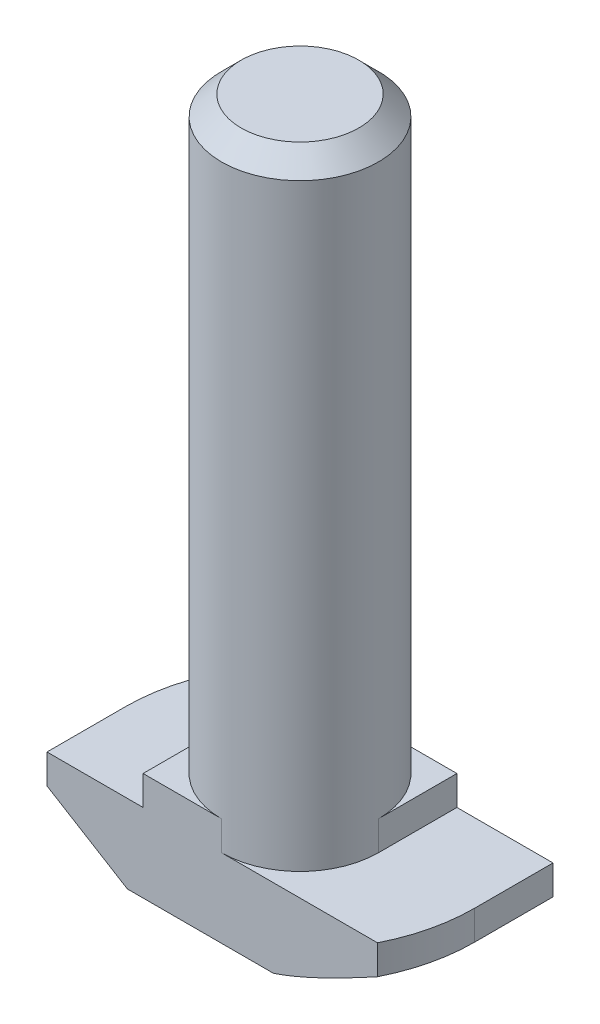
from build123d import *

# Parameters (mm, degrees)
EXTRUDE_1_DEPTH     = 4
CUT_EXTRUDE_1_DEPTH = 1.5
SKETCH_2_R          = 4
EXTRUDE_2_DEPTH     = 30
CUT_EXTRUDE_2_DEPTH = 5
CHAMFER_2_SIZE      = 1


with BuildPart() as part:
    # Эскиз1 → Бобышка-Вытянуть1 (new body, symmetric)
    with BuildSketch(Plane.XY):
        Polygon((8.9, 0), (-8.9, 0), (-8.9, 4), (-4, 4), (-4, 5.5), (4, 5.5), (4, 4), (8.9, 4), align=None)
    extrude(amount=EXTRUDE_1_DEPTH, both=True)

    # Эскиз3 → Вырез-Вытянуть1 (cut)
    with BuildSketch(Plane(origin=(0, 5.5, 0), x_dir=(1, 0, 0), z_dir=(0, 1, 0))):
        with BuildLine():
            Line((-4, 0), (-4, 4))
            Line((-4, 4), (0, 4))
            ThreePointArc((0, 4), (-2.828427125, 2.828427125), (-4, 0))
        make_face()
        with BuildLine():
            Line((0, -4), (4, -4))
            Line((4, -4), (4, 0))
            ThreePointArc((4, 0), (2.828427125, -2.828427125), (0, -4))
        make_face()
    extrude(amount=-CUT_EXTRUDE_1_DEPTH, mode=Mode.SUBTRACT)

    # Эскиз2 → Бобышка-Вытянуть2 (add)
    with BuildSketch(Plane(origin=(0, 5.5, 0), x_dir=(1, 0, 0), z_dir=(0, 1, 0))):
        with Locations(Location((0, 0, 0), (0, 0, 270))):  # turned: the seam where the file's is
            Circle(SKETCH_2_R)
    extrude(amount=EXTRUDE_2_DEPTH)

    # Эскиз4 → Вырез-Вытянуть2 (cut, through all)
    with BuildSketch(Plane(origin=(0, 4, 0), x_dir=(1, 0, 0), z_dir=(0, 1, 0))):
        with BuildLine():
            Line((-7.950471684, 4), (-8.9, 4))
            Line((-8.9, 4), (-8.9, 0))
            ThreePointArc((-8.9, 0), (-8.659364815, 2.055578022), (-7.950471684, 4))
        make_face()
        with BuildLine():
            Line((7.950471684, -4), (8.9, -4))
            Line((8.9, -4), (8.9, 0))
            ThreePointArc((8.9, 0), (8.659364815, -2.055578022), (7.950471684, -4))
        make_face()
    extrude(amount=-CUT_EXTRUDE_2_DEPTH, mode=Mode.SUBTRACT)

    # Вырез-По траектории1: sweep along a path in Эскиз6
    with BuildLine(Plane.XZ) as sweep_1_path:
        Line((0, -8.9), (8.9, -8.9))
        Line((8.9, -8.9), (8.9, 0))
        ThreePointArc((8.9, 0), (6.293250353, 6.293250353), (0, 8.9))
        Line((0, 8.9), (-8.9, 8.9))
        Line((-8.9, 8.9), (-8.9, 0))
        ThreePointArc((-8.9, 0), (-6.293250353, -6.293250353), (0, -8.9))
    # Эскиз5 → Вырез-По траектории1 (sweep, cut)
    with BuildSketch(Plane.XY.offset(4)):
        Polygon((-8.9, 2.5), (-4.8, 0), (-8.9, 0), align=None)
    sweep(path=sweep_1_path.line, transition=Transition.RIGHT, mode=Mode.SUBTRACT)

    # Фаска2
    chamfer_2_edges = [part.edges().sort_by_distance(p)[0] for p in [
        (0, 35.5, -4),
    ]]
    chamfer(chamfer_2_edges, length=CHAMFER_2_SIZE)


solid = part.part
